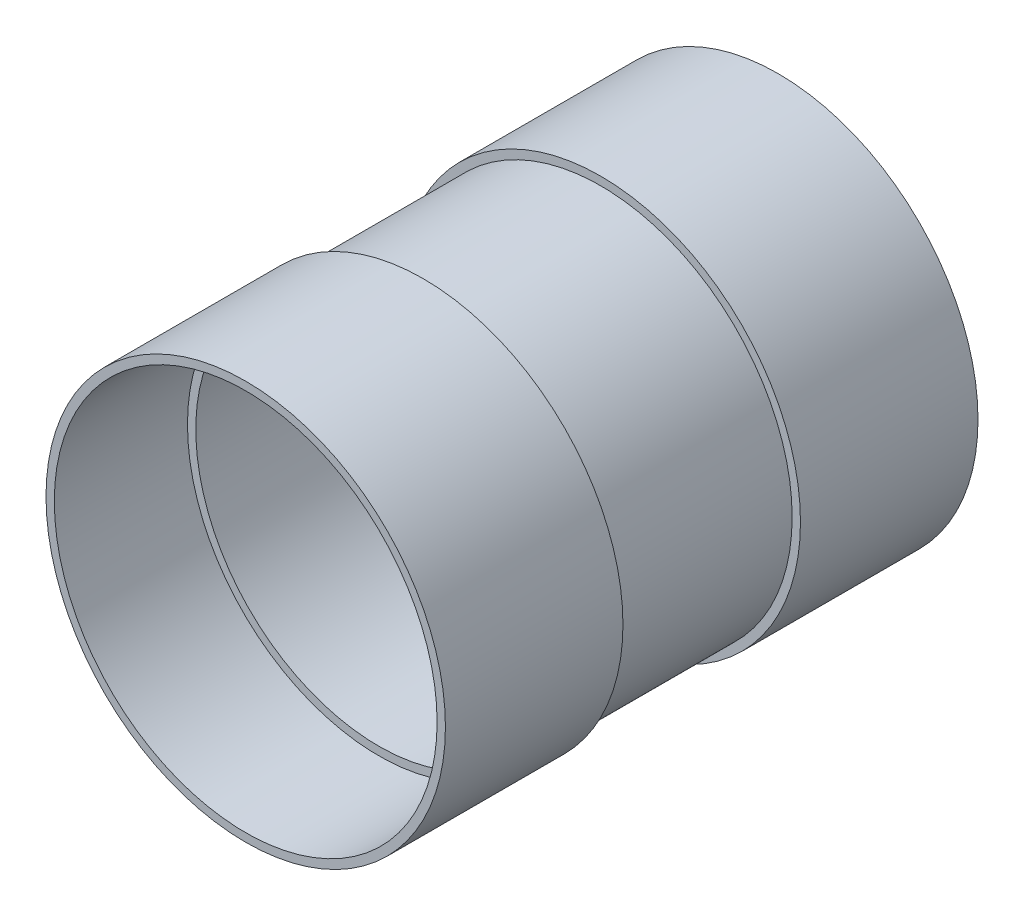
from build123d import *

# Parameters (mm, degrees)
SKETCH2_W = 101.6
SKETCH2_H = 4.7625
SKETCH3_W = 152.4
SKETCH3_H = 4.7625


with BuildPart() as part:
    # Sketch2 → Revolve1 (revolve)
    with BuildSketch(Plane(origin=(0, 0, 0), x_dir=(0, 0, -1), z_dir=(1, 0, 0)), mode=Mode.PRIVATE) as revolve1_sk:
        with Locations((-101.6, 111.91875)):
            Rectangle(SKETCH2_W, SKETCH2_H)
        with Locations((101.6, 111.91875)):
            Rectangle(SKETCH2_W, SKETCH2_H)
    revolve(revolve1_sk.sketch.rotate(Axis((0, 0, 62.594581749), (0, 0, -1)), 90), axis=Axis((0, 0, 62.594581749), (0, 0, -1)))  # turned: the seam where the file's is


with BuildPart() as body_2:
    # Sketch3 → Revolve2 (revolve)
    with BuildSketch(Plane(origin=(0, 0, 0), x_dir=(0, 0, -1), z_dir=(1, 0, 0)), mode=Mode.PRIVATE) as revolve2_sk:
        with Locations((0, 107.15625)):
            Rectangle(SKETCH3_W, SKETCH3_H)
    revolve(revolve2_sk.sketch.rotate(Axis((0, 0, 0), (0, 0, -1)), 90), axis=Axis((0, 0, 0), (0, 0, -1)))  # turned: the seam where the file's is


solid = Compound([part.part, body_2.part])
